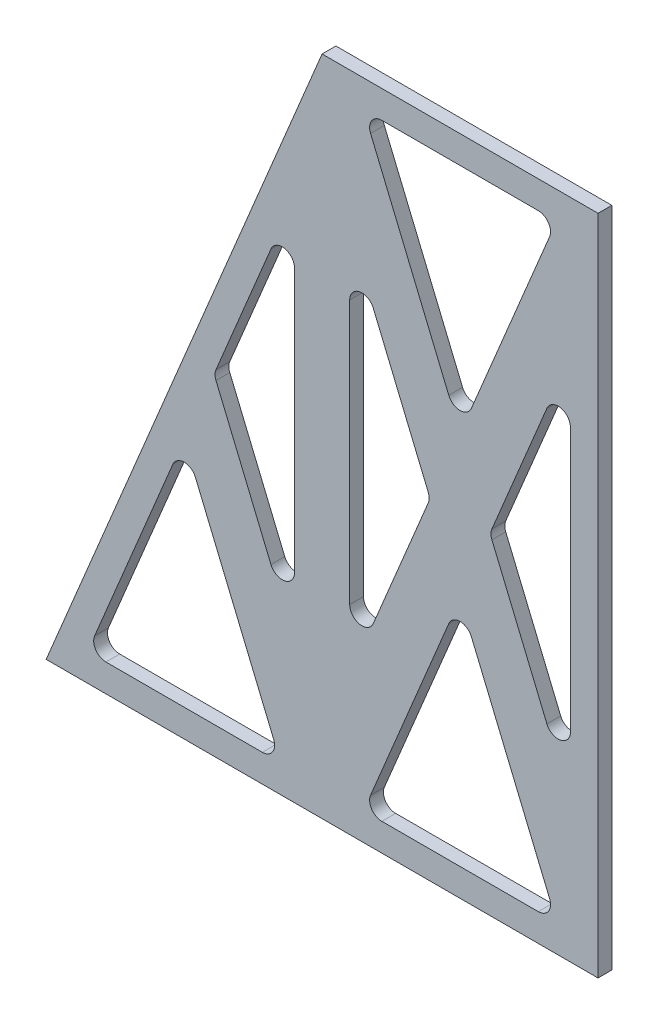
from build123d import *

# Parameters (mm, degrees)
BOSS_EXTRUDE1_DEPTH = 1.5875
CUT_EXTRUDE1_DEPTH  = 5.08


with BuildPart() as part:
    # Sketch2 → Boss-Extrude1 (new body, symmetric)
    with BuildSketch(Plane.XY):
        Polygon((-31.75, -76.2), (-95.25, -76.2), (-31.75, 76.2), (31.75, 76.2), (31.75, -76.2), align=None)
    extrude(amount=BOSS_EXTRUDE1_DEPTH, both=True)

    # Sketch3 → Cut-Extrude1 (cut)
    with BuildSketch(Plane.XY.offset(1.5875)):
        with BuildLine():
            Line((-60.897552188, -22.755874748), (-42.901529882, -65.946328282))
            ThreePointArc((-42.901529882, -65.946328282), (-43.158162937, -68.594558042), (-45.503977694, -69.85))
            Line((-45.503977694, -69.85), (-81.496022306, -69.85))
            ThreePointArc((-81.496022306, -69.85), (-83.841837063, -68.594558042), (-84.098470118, -65.946328282))
            Line((-84.098470118, -65.946328282), (-66.102447812, -22.755874748))
            ThreePointArc((-66.102447812, -22.755874748), (-63.5, -21.020909541), (-60.897552188, -22.755874748))
        make_face()
        with BuildLine():
            ThreePointArc((-25.4, 30.353407686), (-23.133595378, 33.117976889), (-19.978233725, 31.437760941))
            Line((-19.978233725, 31.437760941), (-7.330980523, 1.084353255))
            ThreePointArc((-7.330980523, 1.084353255), (-7.114109872, 0), (-7.330980523, -1.084353255))
            Line((-7.330980523, -1.084353255), (-19.978233725, -31.437760941))
            ThreePointArc((-19.978233725, -31.437760941), (-23.133595378, -33.117976889), (-25.4, -30.353407686))
            Line((-25.4, -30.353407686), (-25.4, 30.353407686))
        make_face()
        with BuildLine():
            ThreePointArc((-20.598470118, 65.946328282), (-20.341837063, 68.594558042), (-17.996022306, 69.85))
            Line((-17.996022306, 69.85), (17.996022306, 69.85))
            ThreePointArc((17.996022306, 69.85), (20.341837063, 68.594558042), (20.598470118, 65.946328282))
            Line((20.598470118, 65.946328282), (2.602447812, 22.755874748))
            ThreePointArc((2.602447812, 22.755874748), (0, 21.020909541), (-2.602447812, 22.755874748))
            Line((-2.602447812, 22.755874748), (-20.598470118, 65.946328282))
        make_face()
        with BuildLine():
            ThreePointArc((-2.602447812, -22.755874748), (0, -21.020909541), (2.602447812, -22.755874748))
            Line((2.602447812, -22.755874748), (20.598470118, -65.946328282))
            ThreePointArc((20.598470118, -65.946328282), (20.341837063, -68.594558042), (17.996022306, -69.85))
            Line((17.996022306, -69.85), (-17.996022306, -69.85))
            ThreePointArc((-17.996022306, -69.85), (-20.341837063, -68.594558042), (-20.598470118, -65.946328282))
            Line((-20.598470118, -65.946328282), (-2.602447812, -22.755874748))
        make_face()
        with BuildLine():
            Line((-38.1, 30.353407686), (-38.1, -30.353407686))
            ThreePointArc((-38.1, -30.353407686), (-40.366404622, -33.117976889), (-43.521766275, -31.437760941))
            Line((-43.521766275, -31.437760941), (-56.169019477, -1.084353255))
            ThreePointArc((-56.169019477, -1.084353255), (-56.385890128, 0), (-56.169019477, 1.084353255))
            Line((-56.169019477, 1.084353255), (-43.521766275, 31.437760941))
            ThreePointArc((-43.521766275, 31.437760941), (-40.366404622, 33.117976889), (-38.1, 30.353407686))
        make_face()
        with BuildLine():
            Line((25.4, -30.353407686), (25.4, 30.353407686))
            ThreePointArc((25.4, 30.353407686), (23.133595378, 33.117976889), (19.978233725, 31.437760941))
            Line((19.978233725, 31.437760941), (7.330980523, 1.084353255))
            ThreePointArc((7.330980523, 1.084353255), (7.114109872, 0), (7.330980523, -1.084353255))
            Line((7.330980523, -1.084353255), (19.978233725, -31.437760941))
            ThreePointArc((19.978233725, -31.437760941), (23.133595378, -33.117976889), (25.4, -30.353407686))
        make_face()
    extrude(amount=-CUT_EXTRUDE1_DEPTH, mode=Mode.SUBTRACT)


solid = part.part
